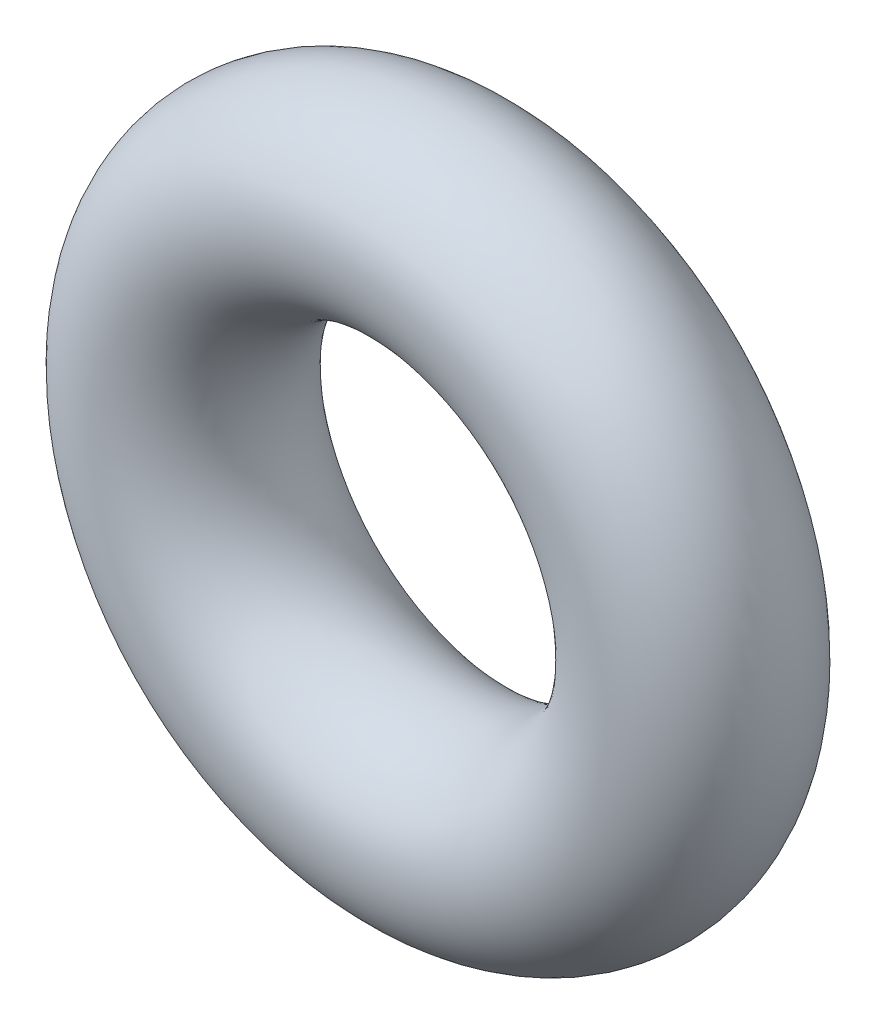
from build123d import *

# Parameters (mm, degrees)
SKETCH1_R = 0.889


with BuildPart() as part:
    # Sketch1 → Revolve1 (revolve)
    with BuildSketch(Plane(origin=(0, 0, 0), x_dir=(0, -1, 0), z_dir=(1, 0, 0))):
        with Locations((2.3368, 0)):
            Circle(SKETCH1_R)
    revolve(axis=Axis((0, 0, 0.889), (0, 0, -1)))


solid = part.part
